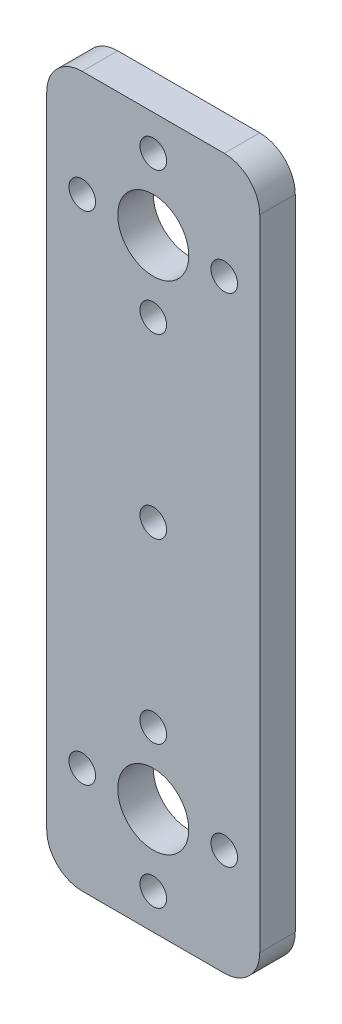
from build123d import *

# Parameters (mm, degrees)
SKETCH1_W           = 24
SKETCH1_H           = 80
BOSS_EXTRUDE1_DEPTH = 4
SKETCH2_R           = 4
SKETCH2_R_2         = 1.5
CUT_EXTRUDE1_DEPTH  = 4
FILLET1_R           = 4
SKETCH3_R           = 1.5
CUT_EXTRUDE2_DEPTH  = 4


with BuildPart() as part:
    # Sketch1 → Boss-Extrude1 (new body)
    with BuildSketch(Plane.XY):
        with Locations((-45.296675466, -5.049681021)):
            Rectangle(SKETCH1_W, SKETCH1_H)
    extrude(amount=BOSS_EXTRUDE1_DEPTH)

    # Sketch2 → Cut-Extrude1 (cut)
    with BuildSketch(Plane.XY.offset(4)):
        with Locations((-45.296675466, -33.049681021)):
            Circle(SKETCH2_R)
        with Locations((-37.296675466, -33.049681021)):
            Circle(SKETCH2_R_2)
        with Locations((-45.296675466, -41.049681021)):
            Circle(SKETCH2_R_2)
        with Locations((-53.296675466, -33.049681021)):
            Circle(SKETCH2_R_2)
        with Locations((-45.296675466, -25.049681021)):
            Circle(SKETCH2_R_2)
        with Locations((-45.296675466, 30.950318979)):
            Circle(SKETCH2_R_2)
        with Locations((-37.296675466, 22.950318979)):
            Circle(SKETCH2_R_2)
        with Locations((-45.296675466, 14.950318979)):
            Circle(SKETCH2_R_2)
        with Locations((-53.296675466, 22.950318979)):
            Circle(SKETCH2_R_2)
        with Locations((-45.296675466, 22.950318979)):
            Circle(SKETCH2_R)
    extrude(amount=-CUT_EXTRUDE1_DEPTH, mode=Mode.SUBTRACT)

    # Fillet1
    fillet1_edges = [part.edges().sort_by_distance(p)[0] for p in [
        (-57.296675466, 34.950318979, 2),
        (-57.296675466, -45.049681021, 2),
        (-33.296675466, -45.049681021, 2),
        (-33.296675466, 34.950318979, 2),
    ]]
    fillet(fillet1_edges, radius=FILLET1_R)

    # Sketch3 → Cut-Extrude2 (cut)
    with BuildSketch(Plane.XY.offset(4)):
        with Locations((-45.296675466, -5.049681021)):
            Circle(SKETCH3_R)
    extrude(amount=-CUT_EXTRUDE2_DEPTH, mode=Mode.SUBTRACT)


solid = part.part
